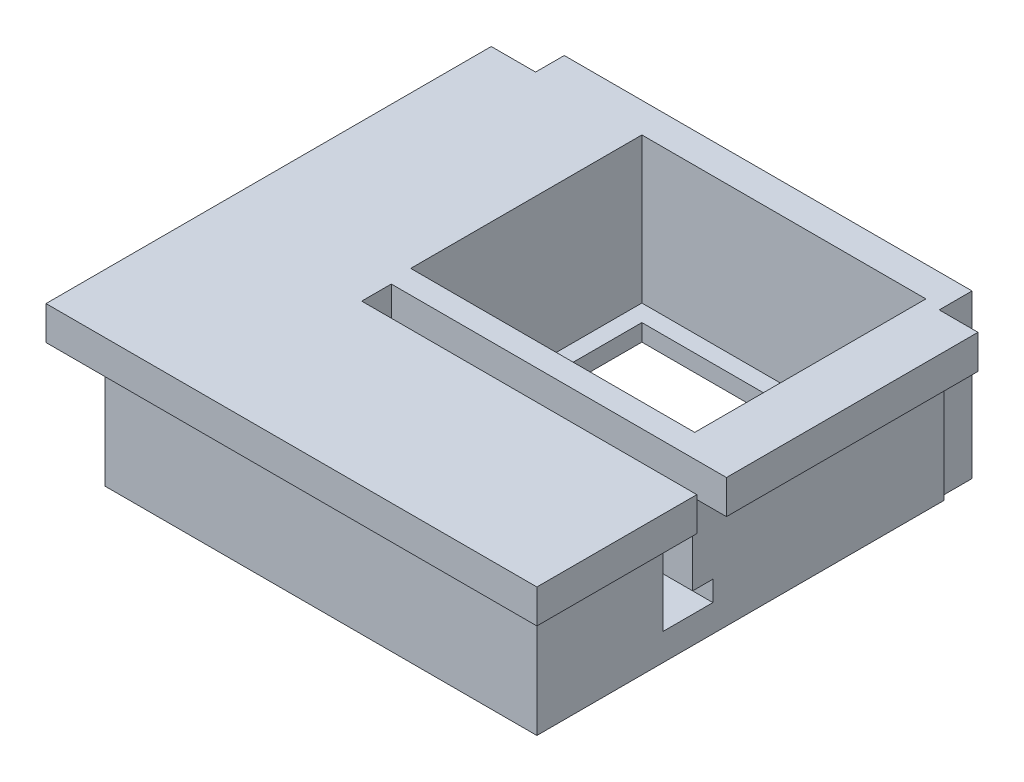
from build123d import *

# Parameters (mm, degrees)
SKETCH4_W                = 25.5
SKETCH4_H                = 26
BOSS_EXTRUDE6_DEPTH      = 9.6
SKETCH17_W               = 1.117177271
SKETCH17_H               = 1.695527899
CUT_EXTRUDE3_DEPTH       = 9.6
SKETCH18_W               = 17.800407573
SKETCH18_H               = 1.75
CUT_EXTRUDE10_DEPTH      = 8
SKETCH20_W               = 16.77875935
SKETCH20_H               = 13.657573424
CUT_EXTRUDE13_DEPTH      = 10.5
SKETCH21_W               = 0.291364414
SKETCH21_H               = 1.940061713
CUT_EXTRUDE14_DEPTH      = 10.5
SKETCH22_W               = 14.860187615
SKETCH22_H               = 2.002394184
BOSS_EXTRUDE7_DEPTH      = 2
SKETCH23_W               = 7.449750672
SKETCH23_H               = 1.995003107
BOSS_EXTRUDE8_DEPTH      = 2
SKETCH24_W               = 27.5
SKETCH24_H               = 1.995003107
BOSS_EXTRUDE9_DEPTH      = 2
SKETCH25_W               = 26.3044721
SKETCH25_H               = 1.995003107
BOSS_EXTRUDE10_DEPTH     = 1.5
SKETCH19_W               = 1.2
SKETCH19_H               = 1.2
CUT_EXTRUDE15_DEPTH      = 3
CUT_EXTRUDE15_DEPTH_BACK = 18.5
SKETCH26_W               = 13.657573424
SKETCH26_H               = 1
BOSS_EXTRUDE11_DEPTH     = 1
SKETCH27_W               = 15.77875935
SKETCH27_H               = 1
BOSS_EXTRUDE12_DEPTH     = 1
SKETCH28_W               = 12.657573424
SKETCH28_H               = 1
BOSS_EXTRUDE13_DEPTH     = 1
SKETCH29_W               = 14.77875935
SKETCH29_H               = 1
BOSS_EXTRUDE14_DEPTH     = 1


with BuildPart() as part:
    # Sketch4 → Boss-Extrude6 (new body)
    with BuildSketch(Plane(origin=(-9.896990102, 0, -25.516417911), x_dir=(1, 0, 0), z_dir=(0, 1, 0))):
        with Locations((-13.336718814, -2.472262581)):
            Rectangle(SKETCH4_W, SKETCH4_H)
    extrude(amount=BOSS_EXTRUDE6_DEPTH)

    # Sketch17 → Cut-Extrude3 (cut)
    with BuildSketch(Plane(origin=(-9.896990102, 9.6, -25.516417911), x_dir=(1, 0, 0), z_dir=(0, 1, 0))):
        with Locations((-25.528130178, 9.67997347)):
            Rectangle(SKETCH17_W, SKETCH17_H)
    extrude(amount=-CUT_EXTRUDE3_DEPTH, mode=Mode.SUBTRACT)

    # Sketch18 → Cut-Extrude10 (cut)
    with BuildSketch(Plane(origin=(-9.896990102, 9.6, -25.516417911), x_dir=(1, 0, 0), z_dir=(0, 1, 0))):
        with Locations((-9.486922601, -7.147511908)):
            Rectangle(SKETCH18_W, SKETCH18_H)
    extrude(amount=-CUT_EXTRUDE10_DEPTH, mode=Mode.SUBTRACT)

    # Sketch20 → Cut-Extrude13 (cut)
    with BuildSketch(Plane(origin=(0, 9.6, -0.078786712), x_dir=(1, 0, 0), z_dir=(0, 1, 0))):
        with Locations((-20.120068773, 27.365205119)):
            Rectangle(SKETCH20_W, SKETCH20_H)
    extrude(amount=-CUT_EXTRUDE13_DEPTH, mode=Mode.SUBTRACT)

    # Sketch21 → Cut-Extrude14 (cut)
    with BuildSketch(Plane(origin=(0, 9.6, 0), x_dir=(1, 0, 0), z_dir=(0, 1, 0))):
        with Locations((-10.629391123, 35.074124474)):
            Rectangle(SKETCH21_W, SKETCH21_H)
    extrude(amount=-CUT_EXTRUDE14_DEPTH, mode=Mode.SUBTRACT)

    # Sketch22 → Boss-Extrude7 (add)
    with BuildSketch(Plane(origin=(-10.483708916, 0, 0), x_dir=(0, 0, -1), z_dir=(1, 0, 0))):
        with Locations((26.67399981, 8.598802908)):
            Rectangle(SKETCH22_W, SKETCH22_H)
    extrude(amount=BOSS_EXTRUDE7_DEPTH)

    # Sketch23 → Boss-Extrude8 (add)
    with BuildSketch(Plane(origin=(-10.483708916, 0, 0), x_dir=(0, 0, -1), z_dir=(1, 0, 0))):
        with Locations((13.769030667, 8.602498447)):
            Rectangle(SKETCH23_W, SKETCH23_H)
    extrude(amount=BOSS_EXTRUDE8_DEPTH)

    # Sketch24 → Boss-Extrude9 (add)
    with BuildSketch(Plane.XY.offset(-10.044155331)):
        with Locations((-22.233708916, 8.602498447)):
            Rectangle(SKETCH24_W, SKETCH24_H)
    extrude(amount=BOSS_EXTRUDE9_DEPTH)

    # Sketch25 → Boss-Extrude10 (add)
    with BuildSketch(Plane.ZY.offset(35.983708916)):
        with Locations((-21.196391381, 8.602498447)):
            Rectangle(SKETCH25_W, SKETCH25_H)
    extrude(amount=BOSS_EXTRUDE10_DEPTH)

    # Sketch19 → Cut-Extrude15 (cut, two sides)
    with BuildSketch(Plane(origin=(-10.483708916, 0, 0), x_dir=(0, 0, -1), z_dir=(1, 0, 0))) as cut_extrude15_sk:
        with Locations((19.843906003, 2.2)):
            Rectangle(SKETCH19_W, SKETCH19_H)
    extrude(amount=CUT_EXTRUDE15_DEPTH, mode=Mode.SUBTRACT)
    extrude(cut_extrude15_sk.sketch, amount=-CUT_EXTRUDE15_DEPTH_BACK, mode=Mode.SUBTRACT)

    # Sketch26 → Boss-Extrude11 (add)
    with BuildSketch(Plane(origin=(-28.509448448, 0, -0.078786712), x_dir=(0, 0, -1), z_dir=(1, 0, 0))):
        with Locations((27.365205119, 0.5)):
            Rectangle(SKETCH26_W, SKETCH26_H)
    extrude(amount=BOSS_EXTRUDE11_DEPTH)

    # Sketch27 → Boss-Extrude12 (add)
    with BuildSketch(Plane.XY.offset(-34.272778542)):
        with Locations((-19.620068773, 0.5)):
            Rectangle(SKETCH27_W, SKETCH27_H)
    extrude(amount=BOSS_EXTRUDE12_DEPTH)

    # Sketch28 → Boss-Extrude13 (add)
    with BuildSketch(Plane(origin=(-11.730689098, 0, -0.078786712), x_dir=(0, 0, 1), z_dir=(-1, 0, 0))):
        with Locations((-26.865205119, 0.5)):
            Rectangle(SKETCH28_W, SKETCH28_H)
    extrude(amount=BOSS_EXTRUDE13_DEPTH)

    # Sketch29 → Boss-Extrude14 (add)
    with BuildSketch(Plane(origin=(0, 0, -20.615205119), x_dir=(-1, 0, 0), z_dir=(0, 0, -1))):
        with Locations((20.120068773, 0.5)):
            Rectangle(SKETCH29_W, SKETCH29_H)
    extrude(amount=BOSS_EXTRUDE14_DEPTH)


solid = part.part
